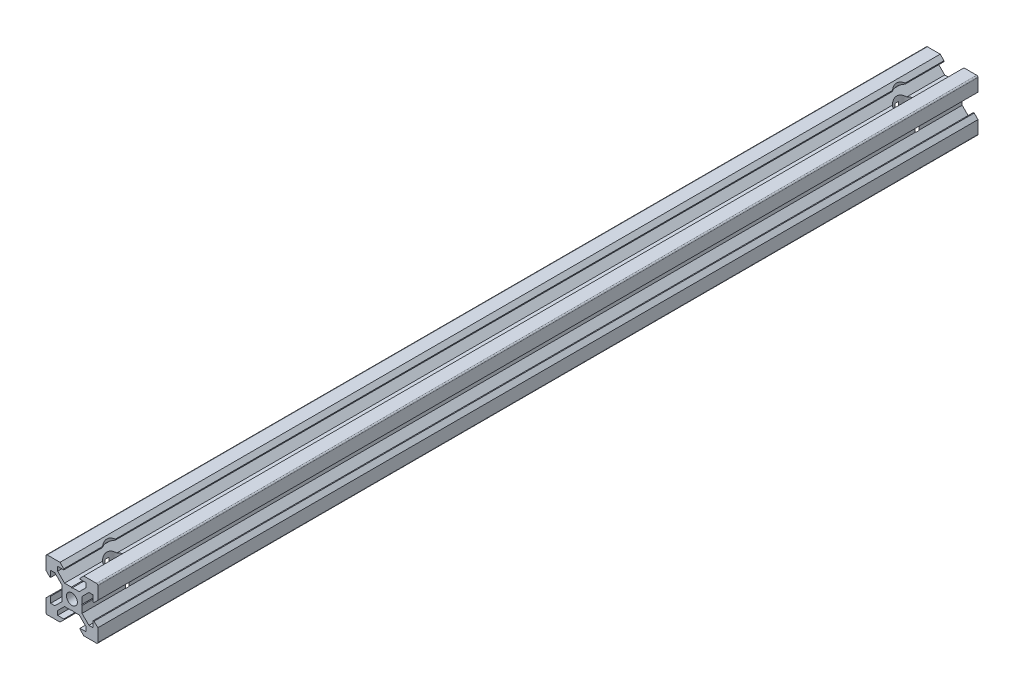
from build123d import *

# Parameters (mm, degrees)
SKETCH1_R                 = 2.1
BOSS_EXTRUDE1_DEPTH       = 500
SKETCH2_R                 = 3.96875
CUT_EXTRUDE1_DEPTH        = 20
M5X0_8_TAPPED_HOLE1_D     = 4.2
M5X0_8_TAPPED_HOLE1_DEPTH = 13.97
M5X0_8_TAPPED_HOLE1_TIP   = 1.2618073
M5X0_8_TAPPED_HOLE2_D     = 4.2
M5X0_8_TAPPED_HOLE2_DEPTH = 13.97
M5X0_8_TAPPED_HOLE2_TIP   = 1.2618073


with BuildPart() as part:
    # Sketch1 → Boss-Extrude1 (new body)
    with BuildSketch(Plane(origin=(0, 0, 0), x_dir=(-1, 0, 0), z_dir=(0, 0, -1))):
        with BuildLine():
            Line((-3.9, -0.21), (-3.9, -2.839339828))
            Line((-3.9, -2.839339828), (-6.560660172, -5.5))
            Line((-6.560660172, -5.5), (-8.2, -5.5))
            Line((-8.2, -5.5), (-8.2, -3.125))
            Line((-8.2, -3.125), (-8.545, -3.125))
            Line((-8.545, -3.125), (-10, -4.58))
            Line((-10, -4.58), (-10, -9.5))
            ThreePointArc((-10, -9.5), (-9.853553391, -9.853553391), (-9.5, -10))
            Line((-9.5, -10), (-4.58, -10))
            Line((-4.58, -10), (-3.125, -8.545))
            Line((-3.125, -8.545), (-3.125, -8.2))
            Line((-3.125, -8.2), (-5.5, -8.2))
            Line((-5.5, -8.2), (-5.5, -6.560660172))
            Line((-5.5, -6.560660172), (-2.839339828, -3.9))
            Line((-2.839339828, -3.9), (-0.21, -3.9))
            Line((-0.21, -3.9), (0, -3.69))
            Line((0, -3.69), (0.21, -3.9))
            Line((0.21, -3.9), (2.839339828, -3.9))
            Line((2.839339828, -3.9), (5.5, -6.560660172))
            Line((5.5, -6.560660172), (5.5, -8.2))
            Line((5.5, -8.2), (3.125, -8.2))
            Line((3.125, -8.2), (3.125, -8.545))
            Line((3.125, -8.545), (4.58, -10))
            Line((4.58, -10), (9.5, -10))
            ThreePointArc((9.5, -10), (9.853553391, -9.853553391), (10, -9.5))
            Line((10, -9.5), (10, -4.58))
            Line((10, -4.58), (8.545, -3.125))
            Line((8.545, -3.125), (8.2, -3.125))
            Line((8.2, -3.125), (8.2, -5.5))
            Line((8.2, -5.5), (6.560660172, -5.5))
            Line((6.560660172, -5.5), (3.9, -2.839339828))
            Line((3.9, -2.839339828), (3.9, -0.21))
            Line((3.9, -0.21), (3.69, 0))
            Line((3.69, 0), (3.9, 0.21))
            Line((3.9, 0.21), (3.9, 2.839339828))
            Line((3.9, 2.839339828), (6.560660172, 5.5))
            Line((6.560660172, 5.5), (8.2, 5.5))
            Line((8.2, 5.5), (8.2, 3.125))
            Line((8.2, 3.125), (8.545, 3.125))
            Line((8.545, 3.125), (10, 4.58))
            Line((10, 4.58), (10, 9.5))
            ThreePointArc((10, 9.5), (9.853553391, 9.853553391), (9.5, 10))
            Line((9.5, 10), (4.58, 10))
            Line((4.58, 10), (3.125, 8.545))
            Line((3.125, 8.545), (3.125, 8.2))
            Line((3.125, 8.2), (5.5, 8.2))
            Line((5.5, 8.2), (5.5, 6.560660172))
            Line((5.5, 6.560660172), (2.839339828, 3.9))
            Line((2.839339828, 3.9), (0.21, 3.9))
            Line((0.21, 3.9), (0, 3.69))
            Line((0, 3.69), (-0.21, 3.9))
            Line((-0.21, 3.9), (-2.839339828, 3.9))
            Line((-2.839339828, 3.9), (-5.5, 6.560660172))
            Line((-5.5, 6.560660172), (-5.5, 8.2))
            Line((-5.5, 8.2), (-3.125, 8.2))
            Line((-3.125, 8.2), (-3.125, 8.545))
            Line((-3.125, 8.545), (-4.58, 10))
            Line((-4.58, 10), (-9.5, 10))
            ThreePointArc((-9.5, 10), (-9.853553391, 9.853553391), (-10, 9.5))
            Line((-10, 9.5), (-10, 4.58))
            Line((-10, 4.58), (-8.545, 3.125))
            Line((-8.545, 3.125), (-8.2, 3.125))
            Line((-8.2, 3.125), (-8.2, 5.5))
            Line((-8.2, 5.5), (-6.560660172, 5.5))
            Line((-6.560660172, 5.5), (-3.9, 2.839339828))
            Line((-3.9, 2.839339828), (-3.9, 0.21))
            Line((-3.9, 0.21), (-3.69, 0))
            Line((-3.69, 0), (-3.9, -0.21))
        make_face()
        Circle(SKETCH1_R, mode=Mode.SUBTRACT)
    extrude(amount=-BOSS_EXTRUDE1_DEPTH)

    # Split1
    split(bisect_by=Plane.XY.offset(160.350000104), keep=Keep.TOP)

    # Sketch2 → Cut-Extrude1 (cut)
    with BuildSketch(Plane(origin=(0, 10, 0), x_dir=(1, 0, 0), z_dir=(0, 1, 0))):
        with Locations((0, -177.775000052)):
            Circle(SKETCH2_R)
        with Locations((0, -482.575000052)):
            Circle(SKETCH2_R)
    extrude(amount=-CUT_EXTRUDE1_DEPTH, mode=Mode.SUBTRACT)

    # M5x0.8 Tapped Hole1
    with Locations(Plane.XY.offset(500)):
        with Locations((0, 0)):
            Hole(M5X0_8_TAPPED_HOLE1_D / 2, depth=M5X0_8_TAPPED_HOLE1_DEPTH)
            with Locations((0, 0, -(M5X0_8_TAPPED_HOLE1_DEPTH + M5X0_8_TAPPED_HOLE1_TIP / 2))):  # 118° drill point
                Cone(0, M5X0_8_TAPPED_HOLE1_D / 2, M5X0_8_TAPPED_HOLE1_TIP, mode=Mode.SUBTRACT)

    # M5x0.8 Tapped Hole2
    with Locations(Plane(origin=(0, 0, 160.350000104), x_dir=(-1, 0, 0), z_dir=(0, 0, -1))):
        with Locations((0, 0)):
            Hole(M5X0_8_TAPPED_HOLE2_D / 2, depth=M5X0_8_TAPPED_HOLE2_DEPTH)
            with Locations((0, 0, -(M5X0_8_TAPPED_HOLE2_DEPTH + M5X0_8_TAPPED_HOLE2_TIP / 2))):  # 118° drill point
                Cone(0, M5X0_8_TAPPED_HOLE2_D / 2, M5X0_8_TAPPED_HOLE2_TIP, mode=Mode.SUBTRACT)


solid = part.part
